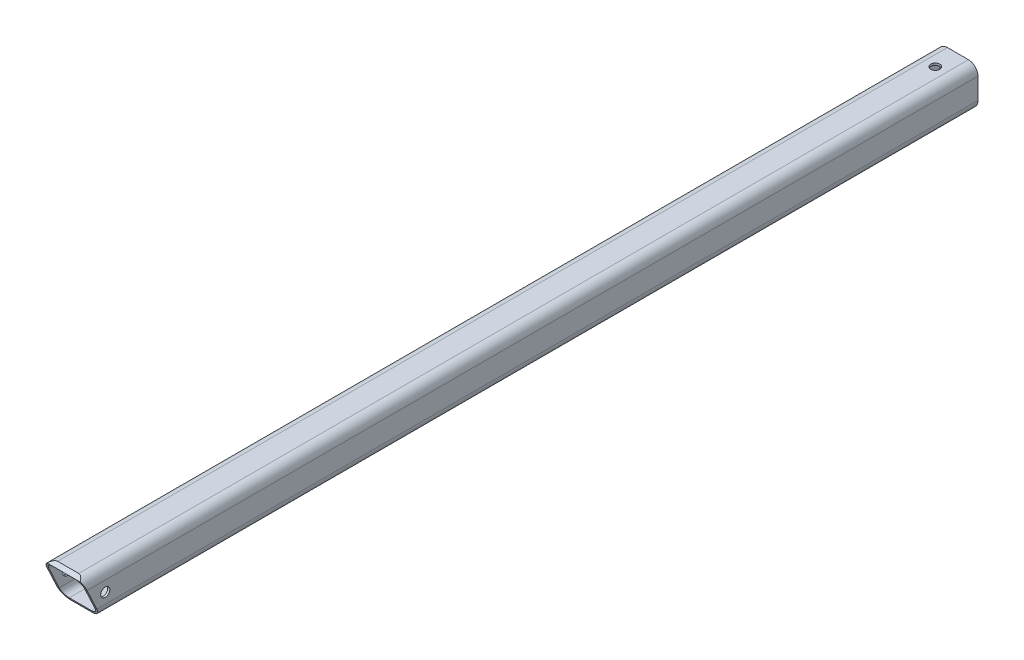
from build123d import *

# Parameters (mm, degrees)
SKETCH4_W                  = 22.4536
SKETCH4_H                  = 22.4536
SKETCH4_W_2                = 20.066
SKETCH4_H_2                = 20.066
BOSS_EXTRUDE2_DEPTH        = 501.65
FILLET2_R                  = 3.81
FILLET1_R                  = 5.334
F_10_CLEARANCE_HOLE1_D     = 5.1054
F_10_CLEARANCE_HOLE1_DEPTH = 16.51
F_10_CLEARANCE_HOLE1_TIP   = 1.533816902
F_10_CLEARANCE_HOLE2_D     = 5.1054
CUT_EXTRUDE1_DEPTH         = 23.4536
CUT_EXTRUDE2_DEPTH         = 23.4536


with BuildPart() as part:
    # Sketch4 → Boss-Extrude2 (new body)
    with BuildSketch(Plane.XY):
        Rectangle(SKETCH4_W, SKETCH4_H)
        Rectangle(SKETCH4_W_2, SKETCH4_H_2, mode=Mode.SUBTRACT)
    extrude(amount=BOSS_EXTRUDE2_DEPTH)

    # Fillet2
    fillet2_edges = [part.edges().sort_by_distance(p)[0] for p in [
        (-10.033, 10.033, 250.825),
        (-10.033, -10.033, 250.825),
        (10.033, -10.033, 250.825),
        (10.033, 10.033, 250.825),
    ]]
    fillet(fillet2_edges, radius=FILLET2_R)

    # Fillet1
    fillet1_edges = [part.edges().sort_by_distance(p)[0] for p in [
        (-11.2268, 11.2268, 250.825),
        (11.2268, 11.2268, 250.825),
        (11.2268, -11.2268, 250.825),
        (-11.2268, -11.2268, 250.825),
    ]]
    fillet(fillet1_edges, radius=FILLET1_R)

    # #10 Clearance Hole1
    with Locations(Plane(origin=(0, 11.2268, 0), x_dir=(1, 0, 0), z_dir=(0, 1, 0))):
        with Locations((0, -12.7)):
            Hole(F_10_CLEARANCE_HOLE1_D / 2, depth=F_10_CLEARANCE_HOLE1_DEPTH)
            with Locations((0, 0, -(F_10_CLEARANCE_HOLE1_DEPTH + F_10_CLEARANCE_HOLE1_TIP / 2))):  # 118° drill point
                Cone(0, F_10_CLEARANCE_HOLE1_D / 2, F_10_CLEARANCE_HOLE1_TIP, mode=Mode.SUBTRACT)

    # #10 Clearance Hole2 (through all)
    with Locations(Plane(origin=(11.2268, 0, 0), x_dir=(0, 0, -1), z_dir=(1, 0, 0))):
        with Locations((-488.95, 0)):
            Hole(F_10_CLEARANCE_HOLE2_D / 2)

    # Sketch10 → Cut-Extrude1 (cut, through all)
    with BuildSketch(Plane.ZY.offset(11.2268)):
        Polygon((501.65, 11.2268), (491.179714367, -11.2268), (501.65, -11.2268), align=None)
    extrude(amount=-CUT_EXTRUDE1_DEPTH, mode=Mode.SUBTRACT)

    # Sketch11 → Cut-Extrude2 (cut, through all)
    with BuildSketch(Plane.ZY.offset(11.2268)):
        Polygon((501.65, 11.2268), (498.533209556, 11.2268), (501.093321918, 10.033), align=None)
    extrude(amount=-CUT_EXTRUDE2_DEPTH, mode=Mode.SUBTRACT)


solid = part.part
